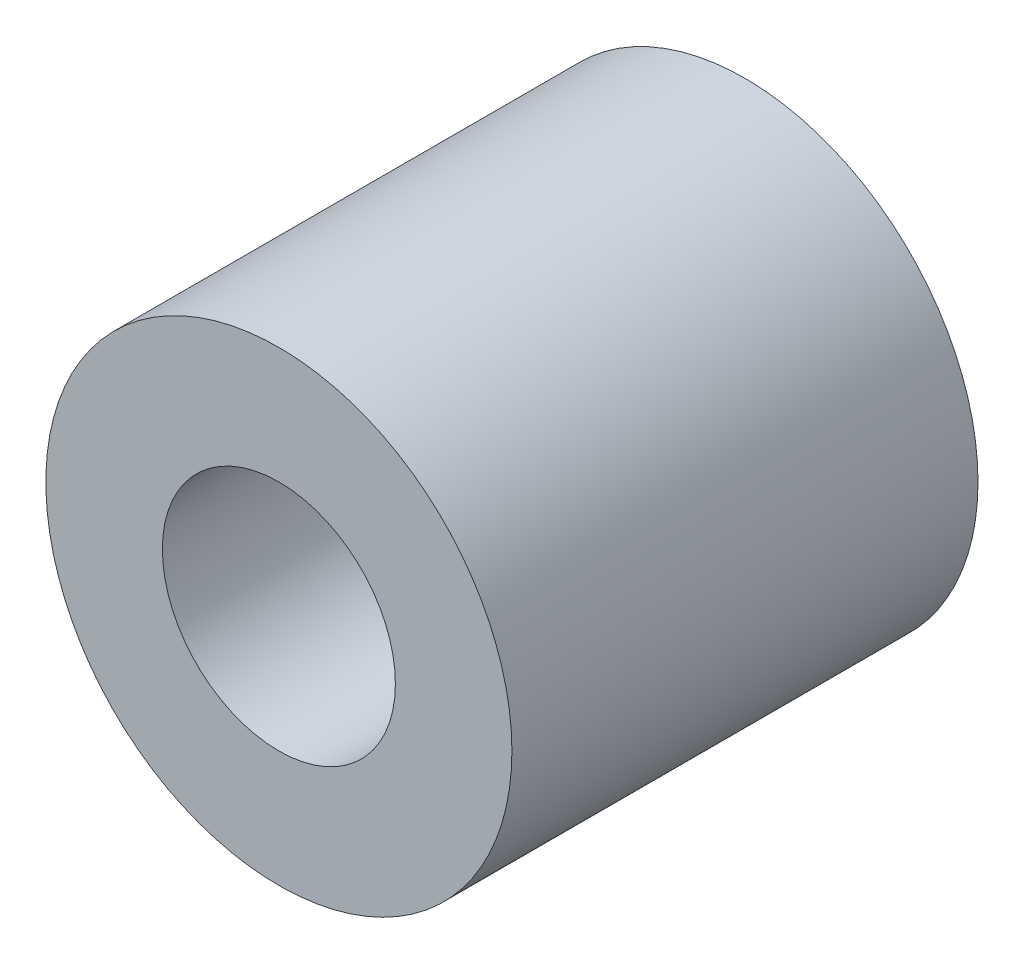
from build123d import *

# Parameters (mm, degrees)
BOSS_EXTRUDE1_START = 15
SKETCH1_R           = 6
BOSS_EXTRUDE1_DEPTH = 12
CUT_EXTRUDE2_DEPTH  = 6
SKETCH2_R           = 3
CUT_EXTRUDE1_DEPTH  = 6


with BuildPart() as part:
    # Sketch1 → Boss-Extrude1 (new body)
    with BuildSketch(Plane.XY.offset(BOSS_EXTRUDE1_START)):
        with Locations((16.35, -29.65)):
            Circle(SKETCH1_R)
    extrude(amount=BOSS_EXTRUDE1_DEPTH)

    # Sketch3 → Cut-Extrude2 (cut)
    with BuildSketch(Plane(origin=(0, 0, 15), x_dir=(-1, 0, 0), z_dir=(0, 0, -1))):
        with BuildLine():
            Line((-18.35, -32.018543856), (-18.35, -27.281456144))
            ThreePointArc((-18.35, -27.281456144), (-13.25, -29.65), (-18.35, -32.018543856))
        make_face()
    extrude(amount=-CUT_EXTRUDE2_DEPTH, mode=Mode.SUBTRACT)

    # Sketch2 → Cut-Extrude1 (cut)
    with BuildSketch(Plane.XY.offset(27)):
        with Locations((16.35, -29.65)):
            Circle(SKETCH2_R)
    extrude(amount=-CUT_EXTRUDE1_DEPTH, mode=Mode.SUBTRACT)


solid = part.part
